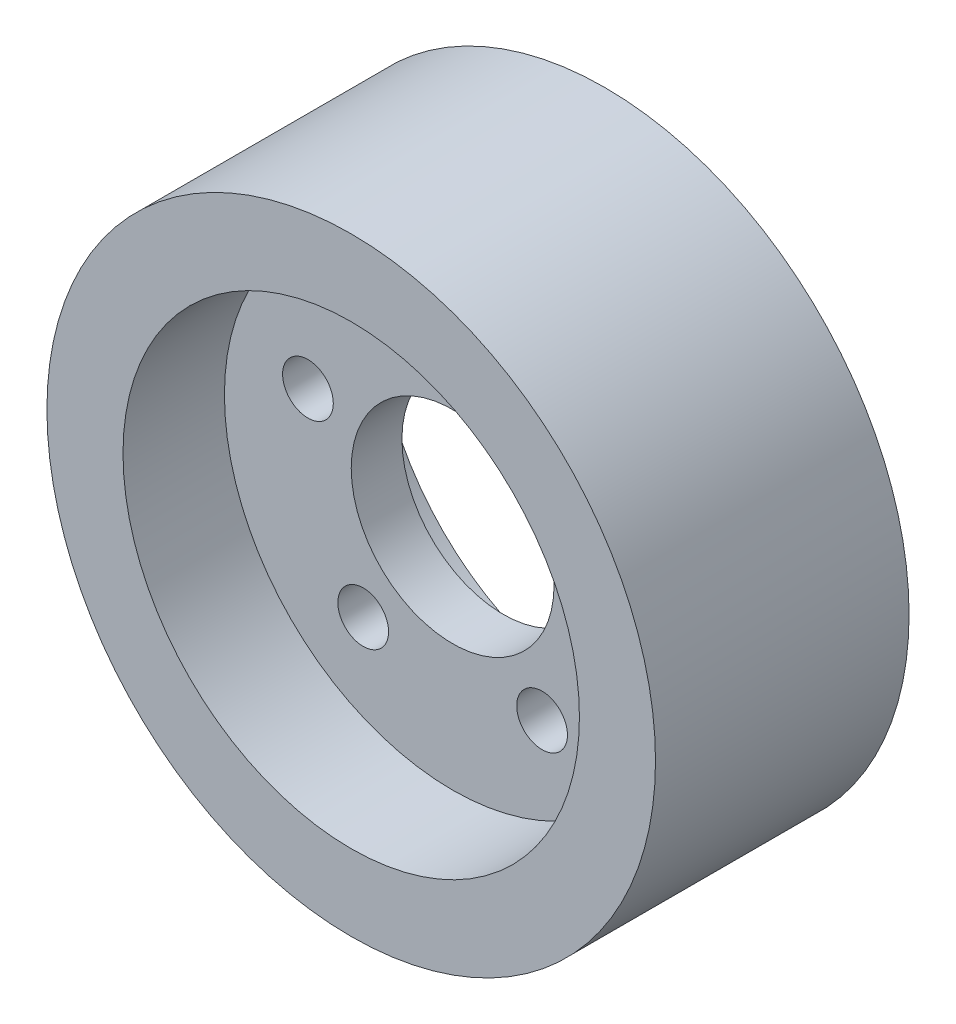
from build123d import *

# Parameters (mm, degrees)
SKETCH1_R           = 30
SKETCH1_R_2         = 10
BOSS_EXTRUDE1_DEPTH = 12.5
SKETCH2_R           = 22.5
CUT_EXTRUDE1_DEPTH  = 10
SKETCH3_R           = 2.5
CUT_EXTRUDE2_DEPTH  = 16
CIRPATTERN3_COUNT   = 5
CIRPATTERN2_COUNT   = 5


with BuildPart() as part:
    # Sketch1 → Boss-Extrude1 (new body, symmetric)
    with BuildSketch(Plane.XY):
        Circle(SKETCH1_R)
        Circle(SKETCH1_R_2, mode=Mode.SUBTRACT)
    extrude(amount=BOSS_EXTRUDE1_DEPTH, both=True)

    # Sketch2 → Cut-Extrude1 (cut)
    with BuildSketch(Plane(origin=(0, 0, -12.5), x_dir=(-1, 0, 0), z_dir=(0, 0, -1))):
        Circle(SKETCH2_R)
    cut_extrude1 = extrude(amount=-CUT_EXTRUDE1_DEPTH, mode=Mode.SUBTRACT)

    # Mirror1: Cut-Extrude1 across plane
    add(cut_extrude1.mirror(Plane.XY), mode=Mode.SUBTRACT)

    # Sketch3 → Cut-Extrude2 (cut, through all)
    with BuildSketch(Plane(origin=(0, 0, -2.5), x_dir=(-1, 0, 0), z_dir=(0, 0, -1))):
        with Locations((0, 15)):
            Circle(SKETCH3_R)
    cut_extrude2 = extrude(amount=-CUT_EXTRUDE2_DEPTH, mode=Mode.SUBTRACT)

    # CirPattern3: Cut-Extrude2 ×5 about axis
    cirpattern3_axis = Axis((0, 0, 0), (0, 0, 1))
    for i in range(1, CIRPATTERN3_COUNT):
        add(cut_extrude2.rotate(cirpattern3_axis, i * 360 / CIRPATTERN3_COUNT), mode=Mode.SUBTRACT)

    # CirPattern2: part ×5 about axis
    cirpattern2_axis = Axis((0, 0, 0), (0, 0, 1))


with BuildPart() as part_1:
    add(part.part)
    for i in range(1, CIRPATTERN2_COUNT):
        add(part.part.rotate(cirpattern2_axis, i * 360 / CIRPATTERN2_COUNT))


solid = part_1.part
